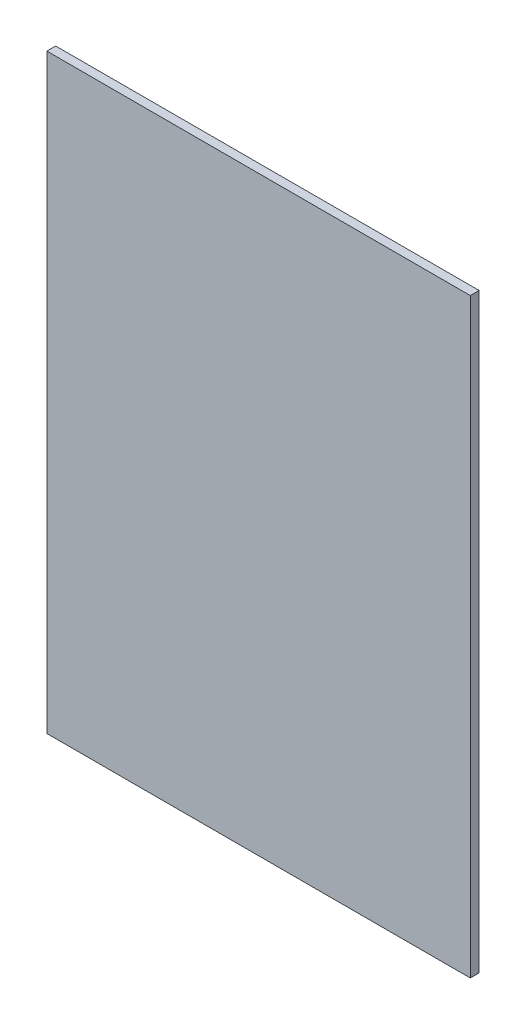
from build123d import *

# Parameters (mm, degrees)
ESQUISSE1_W        = 480
ESQUISSE1_H        = 670
BOSS_EXTRU_1_DEPTH = 10


with BuildPart() as part:
    # Esquisse1 → Boss.-Extru.1 (new body)
    with BuildSketch(Plane.XY):
        with Locations((-50, 0)):
            Rectangle(ESQUISSE1_W, ESQUISSE1_H)
    extrude(amount=BOSS_EXTRU_1_DEPTH)


solid = part.part
